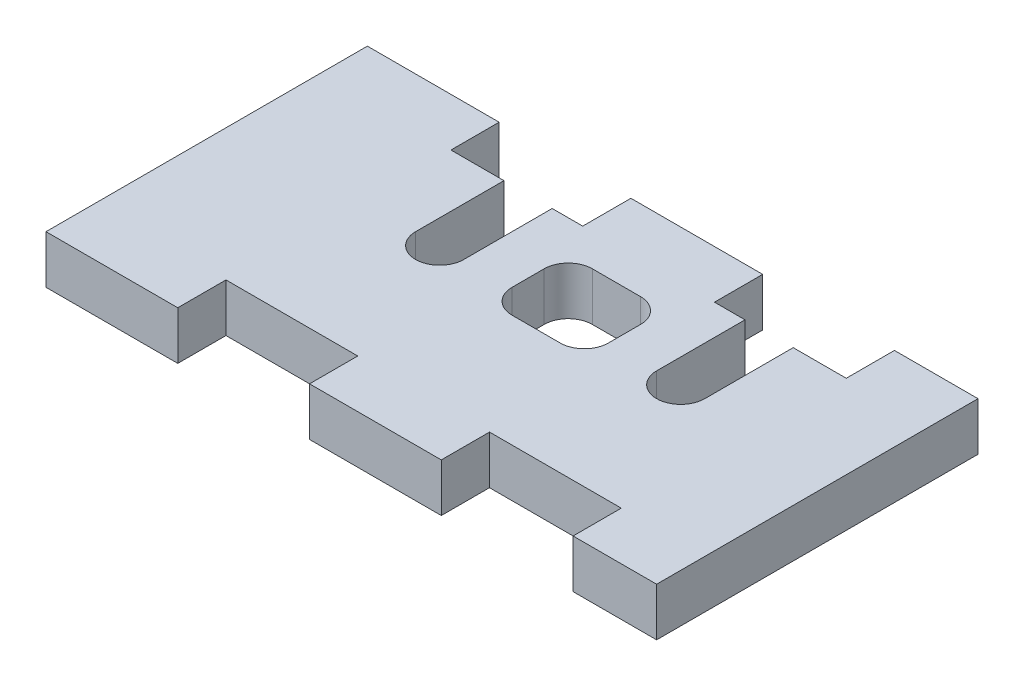
from build123d import *

# Parameters (mm, degrees)
AUFSATZ_LINEAR_AUSTRAGEN1_DEPTH = 3
SCHNITT_LINEAR_AUSTRAGEN1_REACH = 5


with BuildPart() as part:
    # Skizze1 → Aufsatz-Linear austragen1 (new body)
    with BuildSketch(Plane(origin=(0, 0, 0), x_dir=(1, 0, 0), z_dir=(0, 1, 0))):
        Polygon((0, 0), (8.199374, 0), (8.199374, 3.000248), (16.400272, 3.000248), (16.400272, 0), (24.599646, 0), (24.599646, 3.000248), (32.80029, 3.000248), (32.80029, 0), (37.999416, 0), (37.999416, 20), (32.80029, 20), (32.80029, 17.000006), (24.599646, 17.000006), (24.599646, 20), (16.400272, 20), (16.400272, 17.000006), (8.199374, 17.000006), (8.199374, 20), (0, 20), align=None)
    extrude(amount=AUFSATZ_LINEAR_AUSTRAGEN1_DEPTH)

    # Skizze2 → Schnitt-Linear austragen1 (cut, up to next)
    with BuildSketch(Plane.XZ, mode=Mode.PRIVATE) as schnitt_linear_austragen1_sk1:
        with BuildLine():
            Line((11.499959, -20), (11.499959, -11.5))
            ThreePointArc((11.499959, -11.5), (12.999959, -10), (14.499959, -11.5))
            Line((14.499959, -11.5), (14.499959, -20))
            Line((14.499959, -20), (11.499959, -20))
        make_face()
    schnitt_linear_austragen1_tool1 = extrude(schnitt_linear_austragen1_sk1.sketch, amount=-SCHNITT_LINEAR_AUSTRAGEN1_REACH, mode=Mode.PRIVATE) & part.part
    add(schnitt_linear_austragen1_tool1.solids().sort_by_distance((12.999959, 0, -15.155161))[0], mode=Mode.SUBTRACT)
    # Skizze2 → Schnitt-Linear austragen1 (cut, up to next)
    with BuildSketch(Plane.XZ, mode=Mode.PRIVATE) as schnitt_linear_austragen1_sk2:
        with BuildLine():
            Line((26.499959, -20), (29.499959, -20))
            Line((29.499959, -20), (29.499959, -11.5))
            ThreePointArc((29.499959, -11.5), (27.999959, -10), (26.499959, -11.5))
            Line((26.499959, -11.5), (26.499959, -20))
        make_face()
    schnitt_linear_austragen1_tool2 = extrude(schnitt_linear_austragen1_sk2.sketch, amount=-SCHNITT_LINEAR_AUSTRAGEN1_REACH, mode=Mode.PRIVATE) & part.part
    add(schnitt_linear_austragen1_tool2.solids().sort_by_distance((27.999959, 0, -15.155161))[0], mode=Mode.SUBTRACT)
    # Skizze2 → Schnitt-Linear austragen1 (cut, up to next)
    with BuildSketch(Plane.XZ, mode=Mode.PRIVATE) as schnitt_linear_austragen1_sk3:
        with BuildLine():
            Line((18.999959, -10), (21.999959, -10))
            ThreePointArc((21.999959, -10), (23.060619172, -10.439339828), (23.499959, -11.5))
            Line((23.499959, -11.5), (23.499959, -13.500006))
            ThreePointArc((23.499959, -13.500006), (23.060619172, -14.560666172), (21.999959, -15.000006))
            Line((21.999959, -15.000006), (18.999959, -15.000006))
            ThreePointArc((18.999959, -15.000006), (17.939298828, -14.560666172), (17.499959, -13.500006))
            Line((17.499959, -13.500006), (17.499959, -11.5))
            ThreePointArc((17.499959, -11.5), (17.939298828, -10.439339828), (18.999959, -10))
        make_face()
    schnitt_linear_austragen1_tool3 = extrude(schnitt_linear_austragen1_sk3.sketch, amount=-SCHNITT_LINEAR_AUSTRAGEN1_REACH, mode=Mode.PRIVATE) & part.part
    add(schnitt_linear_austragen1_tool3.solids().sort_by_distance((20.499959, 0, -12.500003))[0], mode=Mode.SUBTRACT)


solid = part.part
